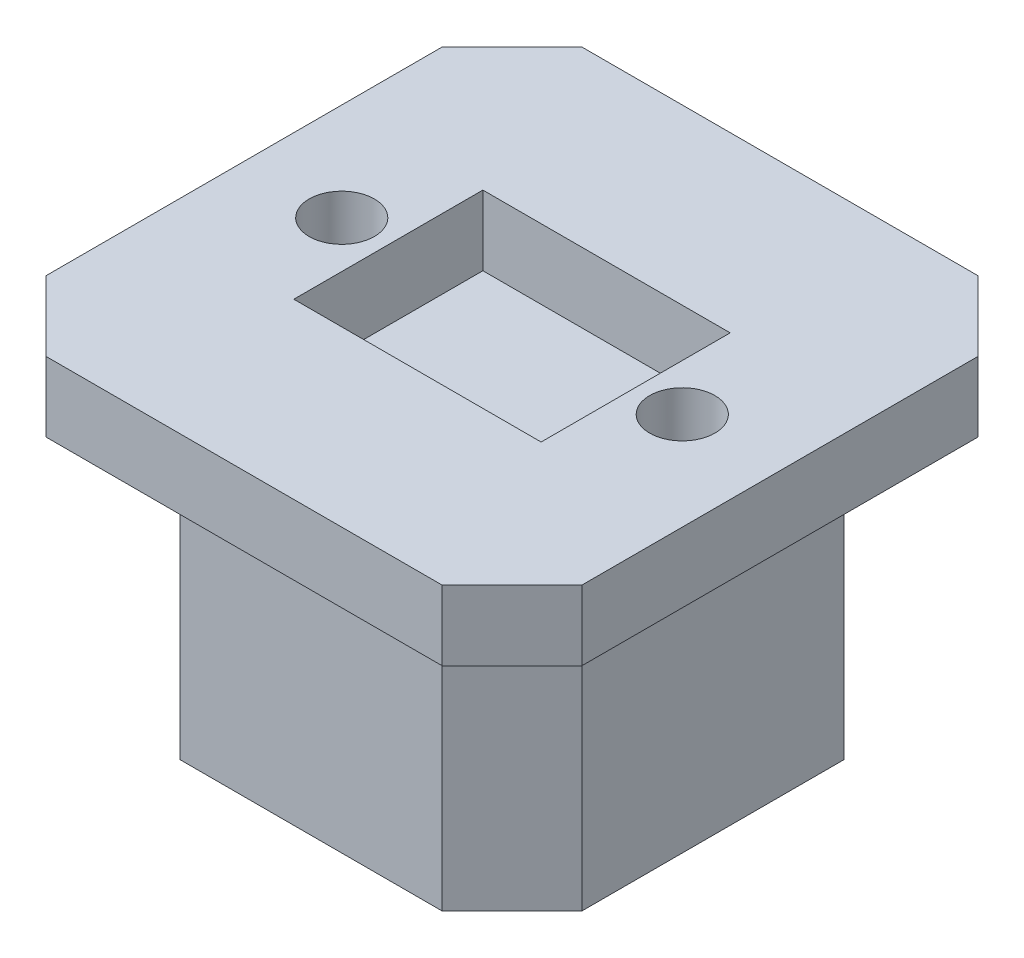
from build123d import *

# Parameters (mm, degrees)
SKETCH1_W           = 38.350231224
SKETCH1_H           = 38.350231224
BOSS_EXTRUDE1_DEPTH = 5
SKETCH2_W           = 28.750231224
SKETCH2_H           = 28.750231224
BOSS_EXTRUDE2_DEPTH = 20
CHAMFER1_SIZE       = 5
SKETCH3_R           = 2.332714882
SKETCH3_W           = 17.69914949
SKETCH3_H           = 13.531318076
CUT_EXTRUDE1_DEPTH  = 5
SKETCH4_R           = 4.319213653
CUT_EXTRUDE2_DEPTH  = 9


with BuildPart() as part:
    # Sketch1 → Boss-Extrude1 (new body)
    with BuildSketch(Plane(origin=(0, 0, 0), x_dir=(1, 0, 0), z_dir=(0, 1, 0))):
        Rectangle(SKETCH1_W, SKETCH1_H)
    extrude(amount=BOSS_EXTRUDE1_DEPTH)

    # Sketch2 → Boss-Extrude2 (add)
    with BuildSketch(Plane(origin=(0, 0, 0), x_dir=(1, 0, 0), z_dir=(0, 1, 0))):
        Rectangle(SKETCH2_W, SKETCH2_H)
    extrude(amount=-BOSS_EXTRUDE2_DEPTH)

    # Chamfer1
    chamfer1_edges = [part.edges().sort_by_distance(p)[0] for p in [
        (14.375115612, -10, -14.375115612),
        (14.375115612, -10, 14.375115612),
        (-14.375115612, -10, 14.375115612),
        (-14.375115612, -10, -14.375115612),
        (19.175115612, 2.5, 19.175115612),
        (-19.175115612, 2.5, 19.175115612),
        (-19.175115612, 2.5, -19.175115612),
        (19.175115612, 2.5, -19.175115612),
    ]]
    chamfer(chamfer1_edges, length=CHAMFER1_SIZE)

    # Sketch3 → Cut-Extrude1 (cut)
    with BuildSketch(Plane(origin=(0, 5, 0), x_dir=(1, 0, 0), z_dir=(0, 1, 0))):
        with Locations((-12.184831311, 0)):
            Circle(SKETCH3_R)
        with Locations((12.184831311, 0)):
            Circle(SKETCH3_R)
        Rectangle(SKETCH3_W, SKETCH3_H)
    extrude(amount=-CUT_EXTRUDE1_DEPTH, mode=Mode.SUBTRACT)

    # Sketch4 → Cut-Extrude2 (cut)
    with BuildSketch(Plane.XZ.offset(20)):
        Circle(SKETCH4_R)
    extrude(amount=-CUT_EXTRUDE2_DEPTH, mode=Mode.SUBTRACT)


solid = part.part
